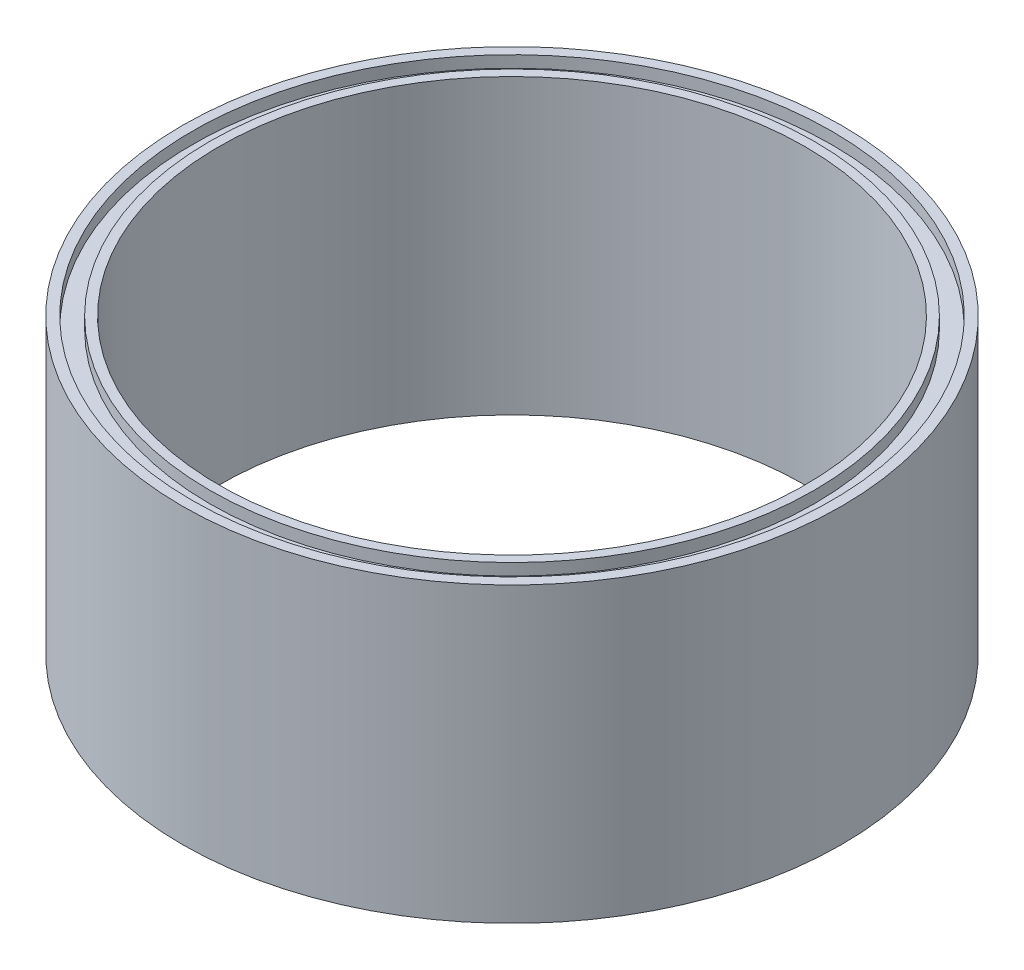
from build123d import *


with BuildPart() as part:
    # Sketch1 → Revolve1 (revolve)
    with BuildSketch(Plane.XY):
        Polygon((-50.8, 0), (-50.8, 50.8), (-52.3875, 50.8), (-52.3875, 48.768), (-55.4355, 48.768), (-55.4355, 50.8), (-57.15, 50.8), (-57.15, 0), (-55.4355, 0), (-55.4355, 2.032), (-52.3875, 2.032), (-52.3875, 0), align=None)
    revolve(axis=Axis((0, 0, 0), (0, 1, 0)))


solid = part.part
